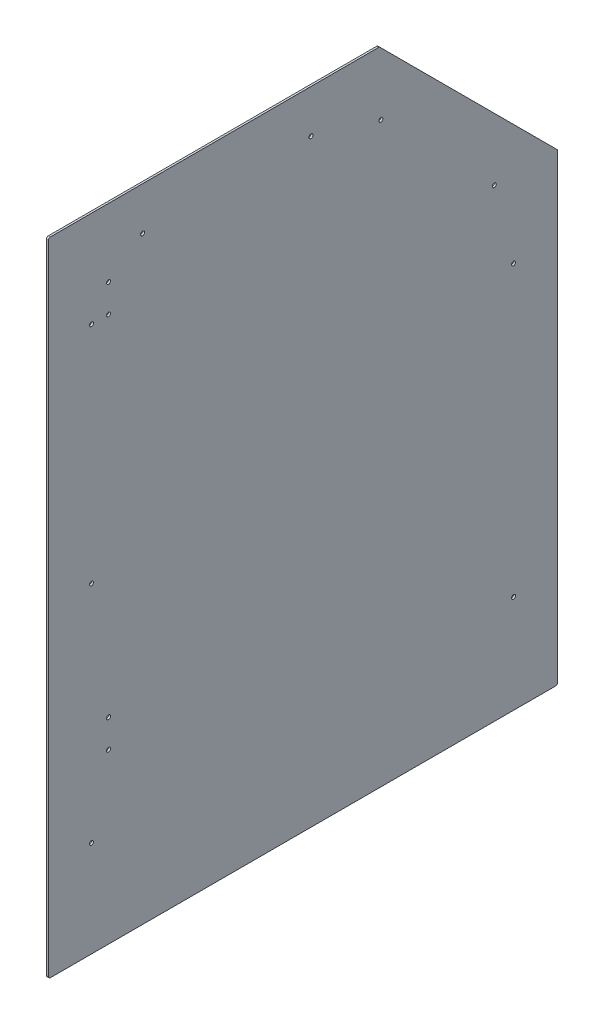
from build123d import *

# Parameters (mm, degrees)
BOSS_EXTRUDE1_DEPTH         = 3.175
F_1_4_0_25_DIAMETER_HOLE1_D = 6.35
FILLET1_R                   = 3.175


with BuildPart() as part:
    # Sketch1 → Boss-Extrude1 (new body)
    with BuildSketch(Plane(origin=(0, 0, 0), x_dir=(0, 0, -1), z_dir=(1, 0, 0))):
        Polygon((0, 0), (0, 1016), (524.232817332, 1016), (806.45, 733.782817332), (806.45, 0), align=None)
    extrude(amount=BOSS_EXTRUDE1_DEPTH)

    # 1/4 (0.25) Diameter Hole1 (through all)
    with Locations(Plane(origin=(3.175, 0, 0), x_dir=(0, 0, -1), z_dir=(1, 0, 0))):
        with Locations((95.25, 908.05), (68.2625, 152.4), (68.2625, 508), (68.2625, 863.6), (149.225, 947.7375), (415.925, 947.7375), (736.6, 155.575), (736.6, 612.775), (706.130949904, 735.319050096), (526.525827482, 914.924172518), (95.25, 266.7), (95.25, 311.15), (95.25, 863.6)):
            Hole(F_1_4_0_25_DIAMETER_HOLE1_D / 2)

    # Fillet1
    fillet1_edges = [part.edges().sort_by_distance(p)[0] for p in [
        (1.5875, 0, 0),
        (1.5875, 1016, 0),
        (1.5875, 1016, -524.232817332),
        (1.5875, 733.782817332, -806.45),
        (1.5875, 0, -806.45),
    ]]
    fillet(fillet1_edges, radius=FILLET1_R)


solid = part.part
